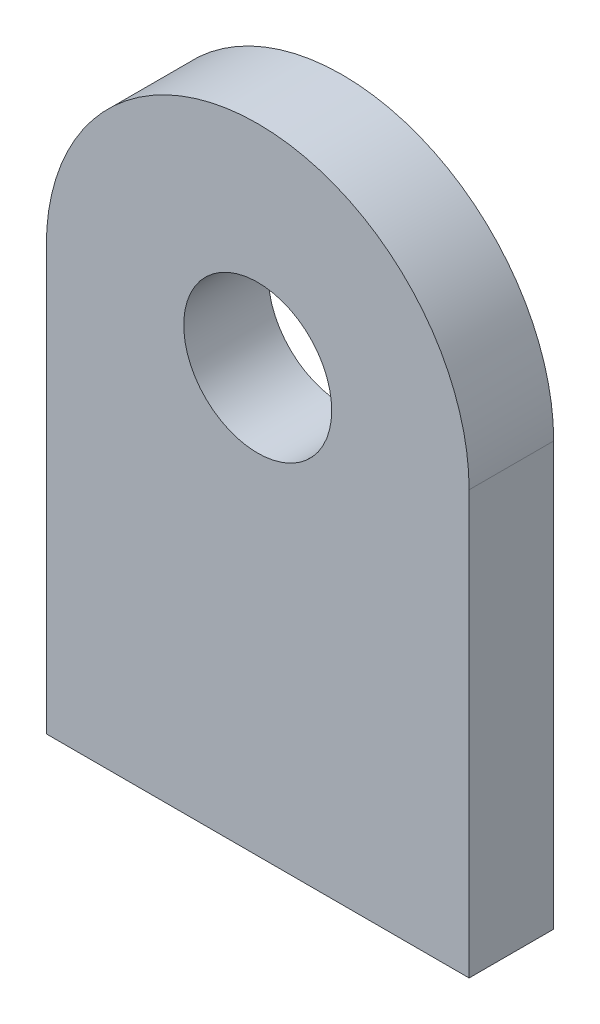
from build123d import *

# Parameters (mm, degrees)
SKETCH1_R           = 17.5
BOSS_EXTRUDE1_DEPTH = 20


with BuildPart() as part:
    # Sketch1 → Boss-Extrude1 (new body)
    with BuildSketch(Plane.XY):
        with BuildLine():
            Line((-50, 100), (-50, 0))
            Line((-50, 0), (50, 0))
            Line((50, 0), (50, 100))
            ThreePointArc((50, 100), (0, 150), (-50, 100))
        make_face()
        with Locations((0, 100)):
            Circle(SKETCH1_R, mode=Mode.SUBTRACT)
    extrude(amount=BOSS_EXTRUDE1_DEPTH)


solid = part.part
